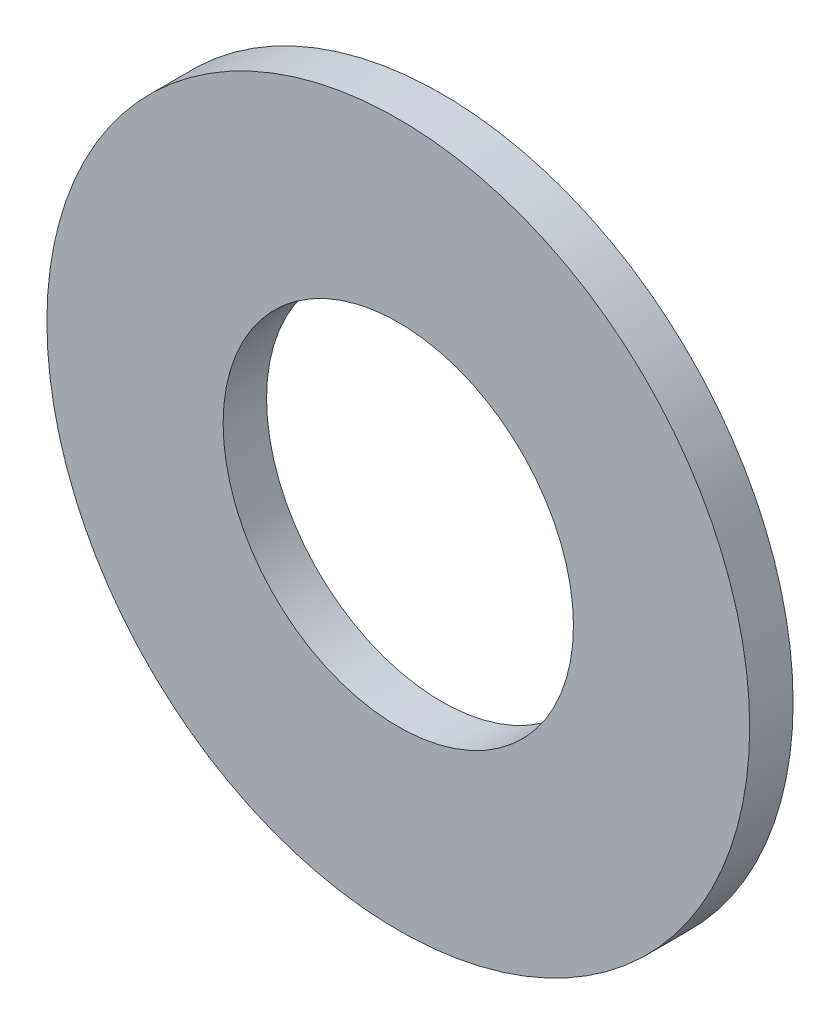
from build123d import *

# Parameters (mm, degrees)
SKETCH3_R                = 12.7381
SKETCH3_R_2              = 6.35
BOSS_EXTRUDE1_DEPTH      = 0.7874
BOSS_EXTRUDE1_DEPTH_BACK = 0.7874


with BuildPart() as part:
    # Sketch3 → Boss-Extrude1 (new body, two sides)
    with BuildSketch(Plane.XY) as boss_extrude1_sk:
        Circle(SKETCH3_R)
        Circle(SKETCH3_R_2, mode=Mode.SUBTRACT)
    extrude(amount=BOSS_EXTRUDE1_DEPTH)
    extrude(boss_extrude1_sk.sketch, amount=-BOSS_EXTRUDE1_DEPTH_BACK)


solid = part.part
